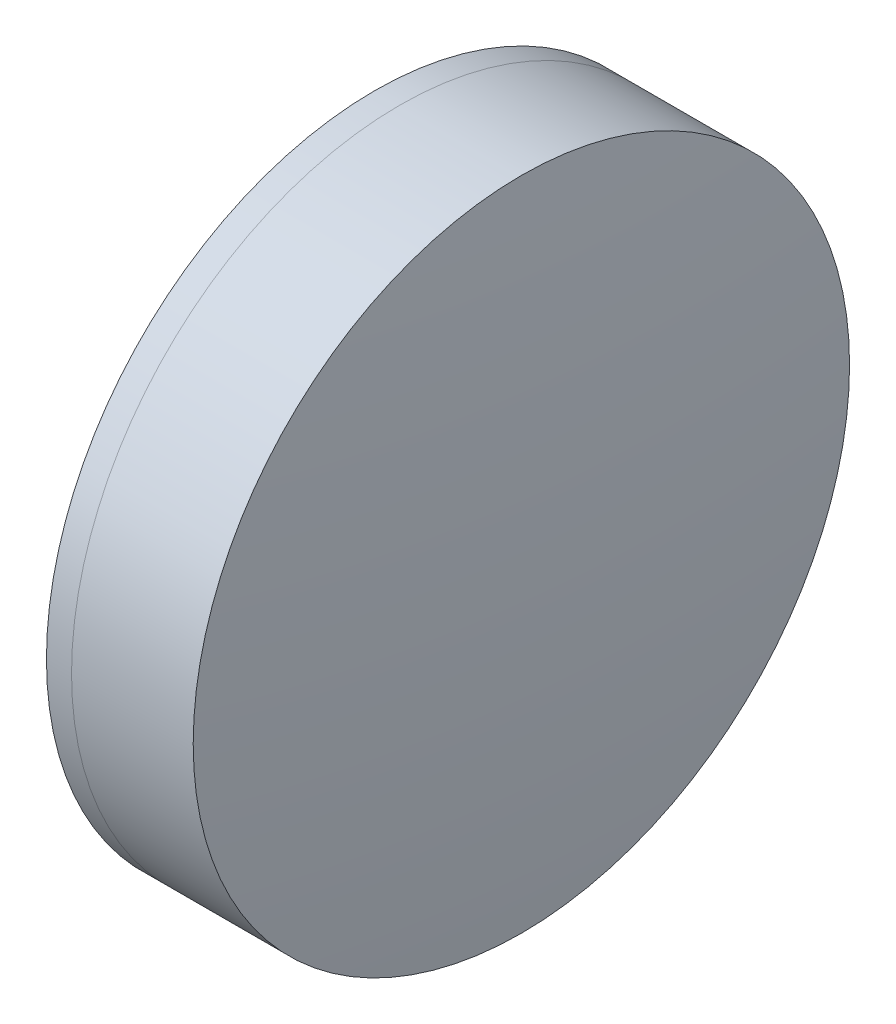
from build123d import *


with BuildPart() as part:
    # 草图1 one side → 旋转1 (revolve)
    with BuildSketch(Plane(origin=(0, 0, 0), x_dir=(1, 0, 0), z_dir=(0, 1, 0)), mode=Mode.PRIVATE) as revolve_1_sk:
        with BuildLine():
            ThreePointArc((232.697600248, 12.7), (230.678758288, 6.492100528), (229.995845808, 0))
            Line((229.995845808, 0), (236.995845808, 0))
            ThreePointArc((236.995845808, 0), (236.150177143, 6.564334039), (233.668395509, 12.7))
            Line((233.668395509, 12.7), (232.697600248, 12.7))
        make_face()
    revolve(revolve_1_sk.sketch.rotate(Axis((-9.702612178, 0, 0), (1, 0, 0)), 180), axis=Axis((-9.702612178, 0, 0), (1, 0, 0)))  # turned: the seam where the file's is


with BuildPart() as body_2:
    # 草图2 one side → 旋转3 (revolve)
    with BuildSketch(Plane(origin=(0, 0, 0), x_dir=(1, 0, 0), z_dir=(0, 1, 0)), mode=Mode.PRIVATE) as revolve_3_sk:
        with BuildLine():
            Line((238.376882887, 12.7), (233.668395509, 12.7))
            ThreePointArc((233.668395509, 12.7), (236.150177143, 6.564334039), (236.995845808, 0))
            Line((236.995845808, 0), (238.995845808, 0))
            ThreePointArc((238.995845808, 0), (238.841013297, 6.357537163), (238.376882887, 12.7))
        make_face()
    revolve(revolve_3_sk.sketch.rotate(Axis((-0.551919993, 0, 0), (1, 0, 0)), 180), axis=Axis((-0.551919993, 0, 0), (1, 0, 0)))  # turned: the seam where the file's is


solid = Compound([part.part, body_2.part])
